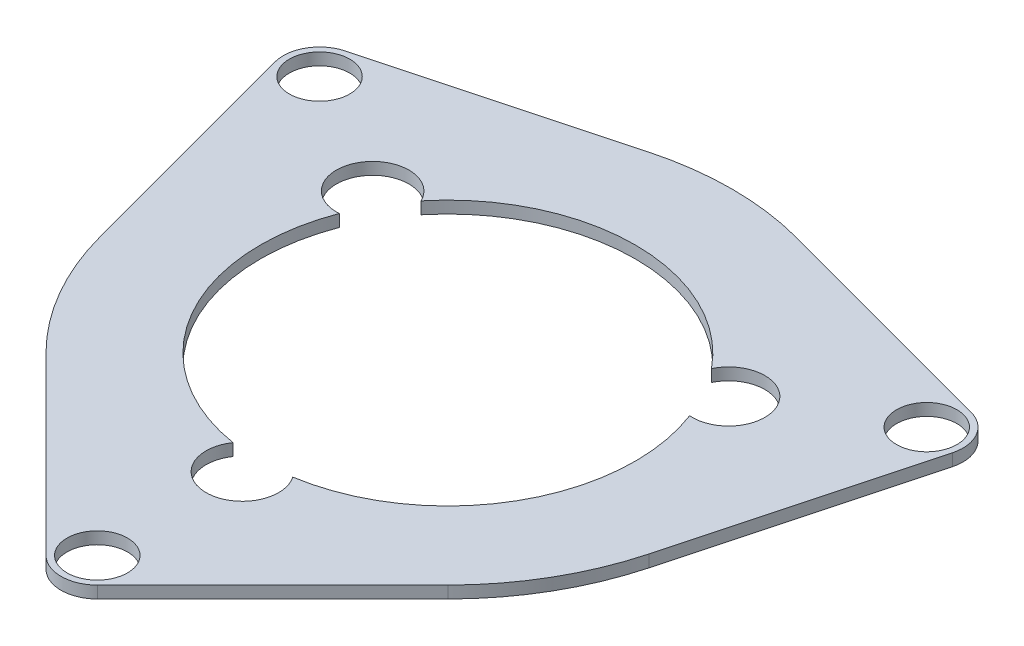
from build123d import *

# Parameters (mm, degrees)
ESQUISSE1_R      = 1.25
EXTRUSION1_DEPTH = 0.5


with BuildPart() as part:
    # Esquisse1 → Extrusion1 (new body)
    with BuildSketch(Plane(origin=(0, 0, 0), x_dir=(1, 0, 0), z_dir=(0, 1, 0))):
        with BuildLine():
            Line((-11.352572917, -3.041912745), (-14.006257094, 6.861771432))
            ThreePointArc((-14.006257094, 6.861771432), (-13.856406461, 8), (-12.945596923, 8.698888739))
            Line((-12.945596923, 8.698888739), (-3.041912745, 11.352572917))
            ThreePointArc((-3.041912745, 11.352572917), (0, 11.753048327), (3.041912745, 11.352572917))
            Line((3.041912745, 11.352572917), (12.945596923, 8.698888739))
            ThreePointArc((12.945596923, 8.698888739), (13.856406461, 8), (14.006257094, 6.861771432))
            Line((14.006257094, 6.861771432), (11.352572917, -3.041912745))
            ThreePointArc((11.352572917, -3.041912745), (10.178438423, -5.876524164), (8.310660172, -8.310660172))
            Line((8.310660172, -8.310660172), (1.060660172, -15.560660172))
            ThreePointArc((1.060660172, -15.560660172), (0, -16), (-1.060660172, -15.560660172))
            Line((-1.060660172, -15.560660172), (-8.310660172, -8.310660172))
            ThreePointArc((-8.310660172, -8.310660172), (-10.178438423, -5.876524164), (-11.352572917, -3.041912745))
        make_face()
        with Locations((-12.557368355, 7.25)):
            Circle(ESQUISSE1_R, mode=Mode.SUBTRACT)
        with Locations((12.557368355, 7.25)):
            Circle(ESQUISSE1_R, mode=Mode.SUBTRACT)
        with Locations((0, -14.5)):
            Circle(ESQUISSE1_R, mode=Mode.SUBTRACT)
        with BuildLine():
            ThreePointArc((-7.243944164, 2.754591249), (-8.660254038, 5), (-6.007518081, 4.896144045))
            ThreePointArc((-6.007518081, 4.896144045), (0, 7.75), (6.007518081, 4.896144045))
            ThreePointArc((6.007518081, 4.896144045), (8.660254038, 5), (7.243944164, 2.754591249))
            ThreePointArc((7.243944164, 2.754591249), (6.711696879, -3.875), (1.236426083, -7.650735294))
            ThreePointArc((1.236426083, -7.650735294), (0, -10), (-1.236426083, -7.650735294))
            ThreePointArc((-1.236426083, -7.650735294), (-6.711696879, -3.875), (-7.243944164, 2.754591249))
        make_face(mode=Mode.SUBTRACT)
    extrude(amount=EXTRUSION1_DEPTH)


solid = part.part
